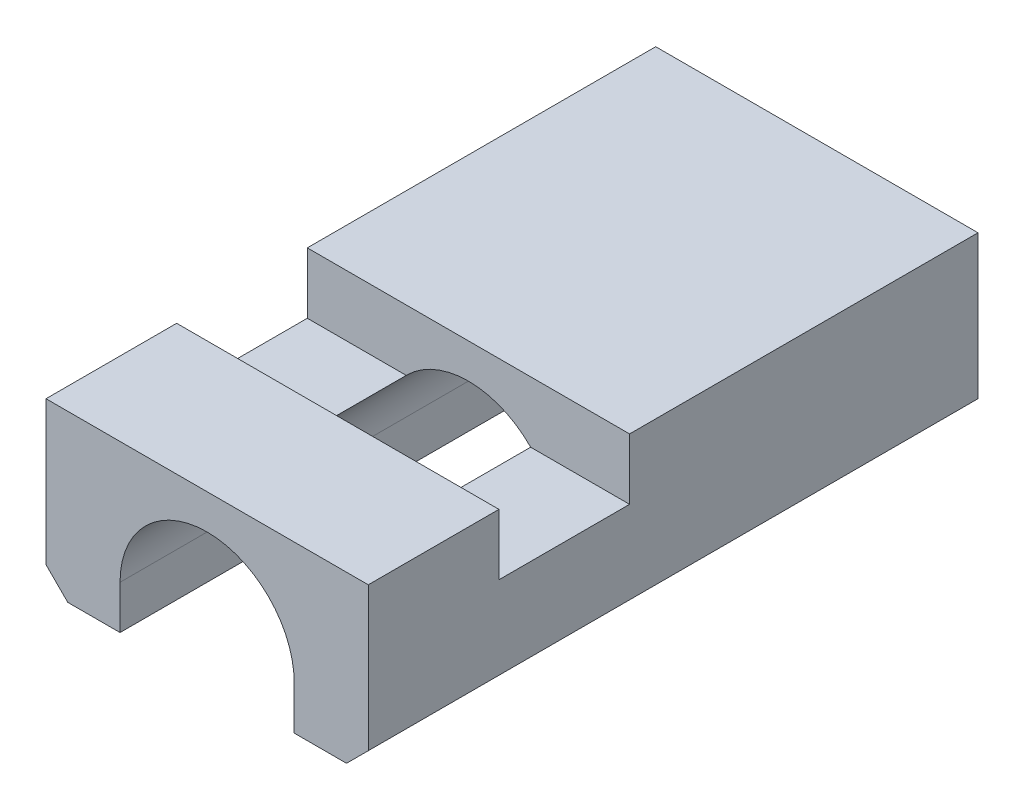
from build123d import *

# Parameters (mm, degrees)
BOSS_EXTRUDE1_DEPTH = 14
CHAMFER1_SIZE       = 0.5
SKETCH2_W           = 3
SKETCH2_H           = 1.4
CUT_EXTRUDE1_DEPTH  = 15


with BuildPart() as part:
    # Sketch1 → Boss-Extrude1 (new body)
    with BuildSketch(Plane.XY):
        with BuildLine():
            Line((-26.871279399, 53.748878842), (-26.871279399, 52.748878842))
            Line((-26.871279399, 52.748878842), (-25.171279399, 52.748878842))
            Line((-25.171279399, 52.748878842), (-25.171279399, 53.748878842))
            ThreePointArc((-25.171279399, 53.748878842), (-23.171279399, 55.748878842), (-21.171279399, 53.748878842))
            Line((-21.171279399, 53.748878842), (-21.171279399, 52.748878842))
            Line((-21.171279399, 52.748878842), (-19.471279399, 52.748878842))
            Line((-19.471279399, 52.748878842), (-19.471279399, 53.748878842))
            Line((-19.471279399, 53.748878842), (-19.471279399, 56.548878842))
            Line((-19.471279399, 56.548878842), (-26.871279399, 56.548878842))
            Line((-26.871279399, 56.548878842), (-26.871279399, 53.748878842))
        make_face()
    extrude(amount=BOSS_EXTRUDE1_DEPTH)

    # Chamfer1
    chamfer1_edges = [part.edges().sort_by_distance(p)[0] for p in [
        (-26.871279399, 52.748878842, 7),
        (-19.471279399, 52.748878842, 7),
    ]]
    chamfer(chamfer1_edges, length=CHAMFER1_SIZE)

    # Sketch2 → Cut-Extrude1 (cut)
    with BuildSketch(Plane(origin=(-19.471279399, 0, 0), x_dir=(0, 0, -1), z_dir=(1, 0, 0))):
        with Locations((-9.5, 55.848878842)):
            Rectangle(SKETCH2_W, SKETCH2_H)
    extrude(amount=-CUT_EXTRUDE1_DEPTH, mode=Mode.SUBTRACT)


solid = part.part
